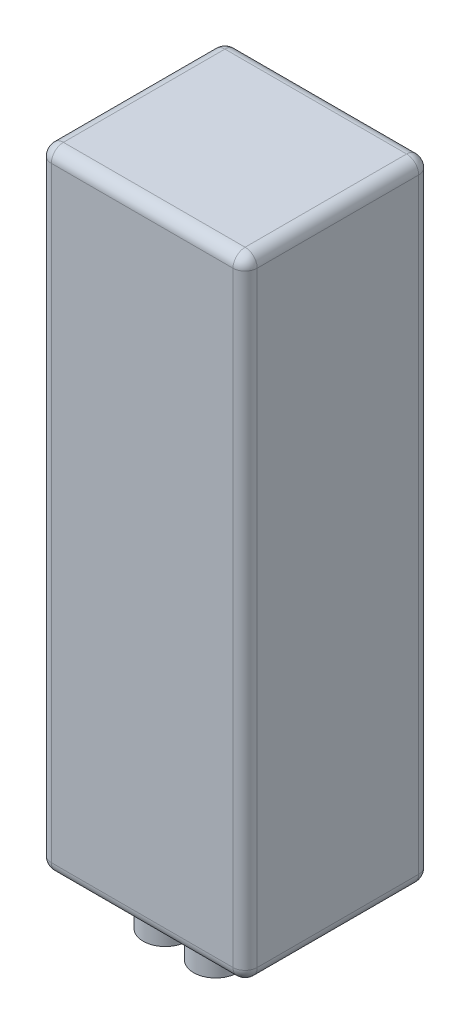
from build123d import *

# Parameters (mm, degrees)
SKETCH1_W           = 51
SKETCH1_H           = 46
BOSS_EXTRUDE1_DEPTH = 156
FILLET1_R           = 3
SKETCH2_R           = 5.479665814
BOSS_EXTRUDE2_DEPTH = 10


with BuildPart() as part:
    # Sketch1 → Boss-Extrude1 (new body)
    with BuildSketch(Plane(origin=(0, 0, 0), x_dir=(1, 0, 0), z_dir=(0, 1, 0))):
        with Locations((-13.995554746, -2.3)):
            Rectangle(SKETCH1_W, SKETCH1_H)
    extrude(amount=BOSS_EXTRUDE1_DEPTH)

    # Fillet1
    fillet1_edges = [part.edges().sort_by_distance(p)[0] for p in [
        (11.504445254, 156, 2.3),
        (-13.995554746, 156, -20.7),
        (-39.495554746, 156, 2.3),
        (-13.995554746, 0, -20.7),
        (11.504445254, 0, 2.3),
        (-13.995554746, 0, 25.3),
        (-39.495554746, 0, 2.3),
        (-39.495554746, 78, -20.7),
        (11.504445254, 78, -20.7),
        (11.504445254, 78, 25.3),
        (-39.495554746, 78, 25.3),
        (-13.995554746, 156, 25.3),
    ]]
    fillet(fillet1_edges, radius=FILLET1_R)

    # Sketch2 → Boss-Extrude2 (add)
    with BuildSketch(Plane.XZ):
        with Locations((-21.241241136, 12.3252816)):
            Circle(SKETCH2_R)
        with Locations((-8.248975885, 12.82498411)):
            Circle(SKETCH2_R)
    extrude(amount=BOSS_EXTRUDE2_DEPTH)


solid = part.part
